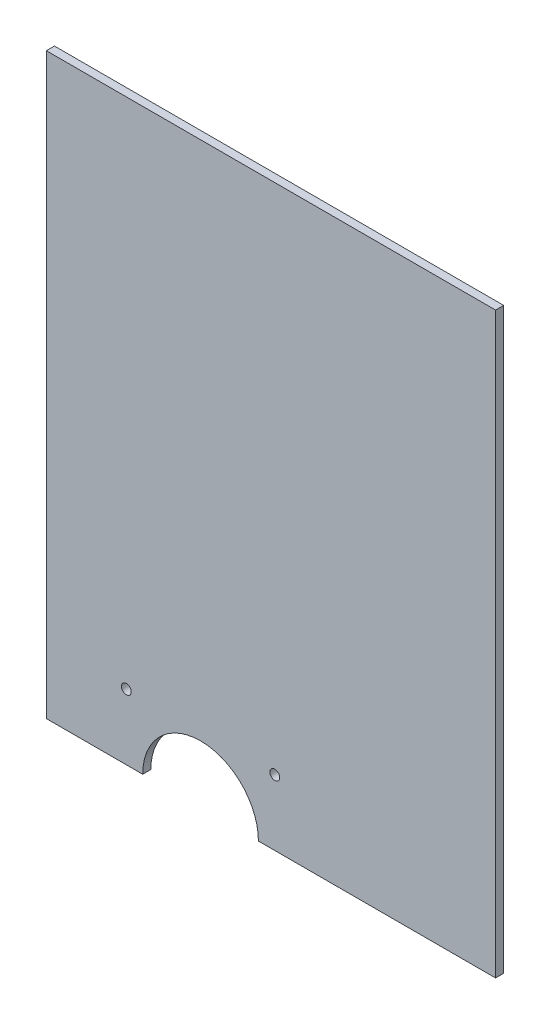
from build123d import *

# Parameters (mm, degrees)
ESQUISSE1_W             = 233
ESQUISSE1_H             = 300
BOSS_EXTRU_1_DEPTH      = 4.2
ESQUISSE2_R             = 2.55
ENL_V_MAT_EXTRU_1_DEPTH = 5.2


with BuildPart() as part:
    # Esquisse1 → Boss.-Extru.1 (new body)
    with BuildSketch(Plane.XY):
        with Locations((-3.063037439, -81.267653759)):
            Rectangle(ESQUISSE1_W, ESQUISSE1_H)
    extrude(amount=BOSS_EXTRU_1_DEPTH)

    # Esquisse2 → Enlèv. mat.-Extru.1 (cut, through all)
    with BuildSketch(Plane.XY.offset(4.2)):
        with Locations((-78.063037439, -197.267653759)):
            Circle(ESQUISSE2_R)
        with Locations((-1.063037439, -197.267653759)):
            Circle(ESQUISSE2_R)
        with BuildLine():
            Line((-69.563037439, -231.267653759), (-9.563037439, -231.267653759))
            ThreePointArc((-9.563037439, -231.267653759), (-39.563037439, -201.267653759), (-69.563037439, -231.267653759))
        make_face()
    extrude(amount=-ENL_V_MAT_EXTRU_1_DEPTH, mode=Mode.SUBTRACT)


solid = part.part
